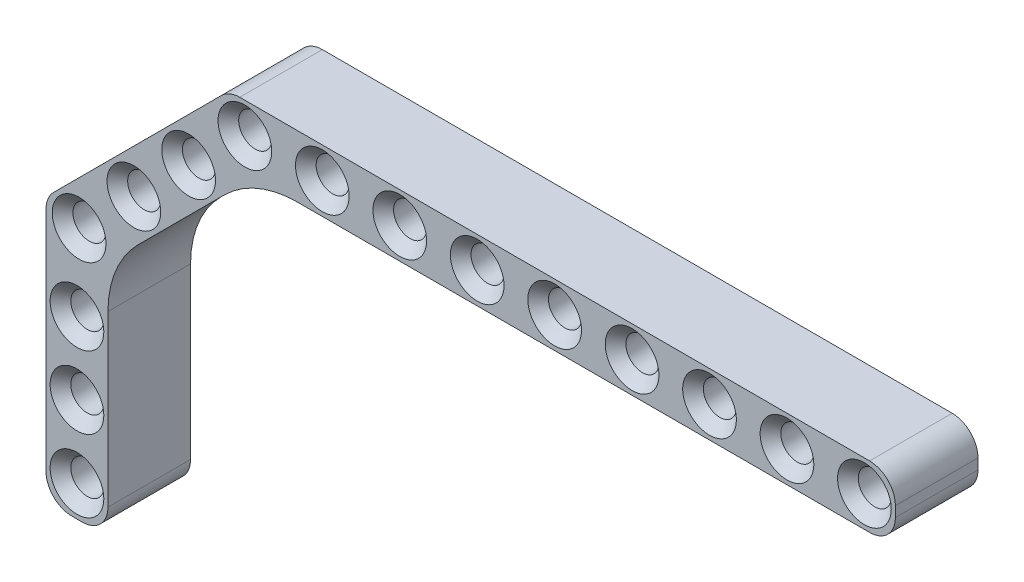
from build123d import *

# Parameters (mm, degrees)
SKETCH1_R           = 1.6
BOSS_EXTRUDE1_DEPTH = 8
CHAMFER1_SIZE       = 1
SKETCH2_R           = 1.6
BOSS_EXTRUDE3_DEPTH = 8
FILLET1_R           = 10
CHAMFER2_SIZE       = 1
CHAMFER3_SIZE       = 1
CHAMFER4_SIZE       = 1
SKETCH3_R           = 1.6
BOSS_EXTRUDE4_DEPTH = 8
CHAMFER5_SIZE       = 1
FILLET2_R           = 10


with BuildPart() as part:
    # Sketch1 → Boss-Extrude1 (new body)
    with BuildSketch(Plane.XY):
        with BuildLine():
            Line((-0.5, 3), (60.5, 3))
            ThreePointArc((60.5, 3), (62.267766953, 2.267766953), (63, 0.5))
            Line((63, 0.5), (63, -0.5))
            ThreePointArc((63, -0.5), (62.267766953, -2.267766953), (60.5, -3))
            Line((60.5, -3), (-0.5, -3))
            ThreePointArc((-0.5, -3), (-2.267766953, -2.267766953), (-3, -0.5))
            Line((-3, -0.5), (-3, 0.5))
            ThreePointArc((-3, 0.5), (-2.267766953, 2.267766953), (-0.5, 3))
        make_face()
        Circle(SKETCH1_R, mode=Mode.SUBTRACT)
        with Locations((7.5, 0)):
            Circle(SKETCH1_R, mode=Mode.SUBTRACT)
        with Locations((15, 0)):
            Circle(SKETCH1_R, mode=Mode.SUBTRACT)
        with Locations((22.5, 0)):
            Circle(SKETCH1_R, mode=Mode.SUBTRACT)
        with Locations((30, 0)):
            Circle(SKETCH1_R, mode=Mode.SUBTRACT)
        with Locations((37.5, 0)):
            Circle(SKETCH1_R, mode=Mode.SUBTRACT)
        with Locations((45, 0)):
            Circle(SKETCH1_R, mode=Mode.SUBTRACT)
        with Locations((52.5, 0)):
            Circle(SKETCH1_R, mode=Mode.SUBTRACT)
        with Locations((60, 0)):
            Circle(SKETCH1_R, mode=Mode.SUBTRACT)
    extrude(amount=BOSS_EXTRUDE1_DEPTH)

    # Chamfer1
    chamfer1_edges = [part.edges().sort_by_distance(p)[0] for p in [
        (-1.6, 0, 0),
        (-1.6, 0, 8),
        (5.9, 0, 0),
        (5.9, 0, 8),
        (13.4, 0, 0),
        (13.4, 0, 8),
        (20.9, 0, 0),
        (20.9, 0, 8),
        (28.4, 0, 0),
        (28.4, 0, 8),
    ]]
    chamfer(chamfer1_edges, length=CHAMFER1_SIZE)

    # Sketch2 → Boss-Extrude3 (add)
    with BuildSketch(Plane.XY.offset(8)):
        with BuildLine():
            ThreePointArc((-3, 0.5), (-2.809698831, 1.456708581), (-2.267766953, 2.267766953))
            Line((-2.267766953, 2.267766953), (-18.529200529, -13.993666623))
            ThreePointArc((-18.529200529, -13.993666623), (-19.261433576, -15.761433576), (-18.529200529, -17.529200529))
            Line((-18.529200529, -17.529200529), (-17.822093748, -18.23630731))
            ThreePointArc((-17.822093748, -18.23630731), (-16.054326795, -18.968540357), (-14.286559842, -18.23630731))
            Line((-14.286559842, -18.23630731), (0.949747468, -3))
            Line((0.949747468, -3), (-0.5, -3))
            ThreePointArc((-0.5, -3), (-2.267766953, -2.267766953), (-3, -0.5))
            Line((-3, -0.5), (-3, 0.5))
        make_face()
        with Locations((-16.054326795, -15.761433576)):
            Circle(SKETCH2_R, mode=Mode.SUBTRACT)
        with Locations((-10.751025936, -10.458132717)):
            Circle(SKETCH2_R, mode=Mode.SUBTRACT)
        with Locations((-5.447725077, -5.154831858)):
            Circle(SKETCH2_R, mode=Mode.SUBTRACT)
    extrude(amount=-BOSS_EXTRUDE3_DEPTH)

    # Fillet1
    fillet1_edges = [part.edges().sort_by_distance(p)[0] for p in [
        (0.949747468, -3, 4),
    ]]
    fillet(fillet1_edges, radius=FILLET1_R)

    # Chamfer2
    chamfer2_edges = [part.edges().sort_by_distance(p)[0] for p in [
        (-17.654326795, -15.761433576, 0),
        (-17.654326795, -15.761433576, 8),
        (-12.351025936, -10.458132717, 8),
        (-7.047725077, -5.154831858, 8),
        (-7.047725077, -5.154831858, 0),
        (-12.351025936, -10.458132717, 0),
    ]]
    chamfer(chamfer2_edges, length=CHAMFER2_SIZE)

    # Chamfer3
    chamfer3_edges = [part.edges().sort_by_distance(p)[0] for p in [
        (35.9, 0, 0),
        (35.9, 0, 8),
        (43.4, 0, 0),
        (43.4, 0, 8),
    ]]
    chamfer(chamfer3_edges, length=CHAMFER3_SIZE)

    # Chamfer4
    chamfer4_edges = [part.edges().sort_by_distance(p)[0] for p in [
        (50.9, 0, 0),
        (50.9, 0, 8),
        (58.4, 0, 0),
        (58.4, 0, 8),
    ]]
    chamfer(chamfer4_edges, length=CHAMFER4_SIZE)

    # Sketch3 → Boss-Extrude4 (add)
    with BuildSketch(Plane.XY.offset(8)):
        with BuildLine():
            ThreePointArc((-18.529200529, -17.529200529), (-19.071132407, -16.718142157), (-19.261433576, -15.761433576))
            Line((-19.261433576, -15.761433576), (-19.261433576, -37.761433576))
            ThreePointArc((-19.261433576, -37.761433576), (-18.529200529, -39.529200529), (-16.761433576, -40.261433576))
            Line((-16.761433576, -40.261433576), (-15.761433576, -40.261433576))
            ThreePointArc((-15.761433576, -40.261433576), (-13.993666623, -39.529200529), (-13.261433576, -37.761433576))
            Line((-13.261433576, -37.761433576), (-13.261433576, -17.211181044))
            Line((-13.261433576, -17.211181044), (-14.286559842, -18.23630731))
            ThreePointArc((-14.286559842, -18.23630731), (-16.054326795, -18.968540357), (-17.822093748, -18.23630731))
            Line((-17.822093748, -18.23630731), (-18.529200529, -17.529200529))
        make_face()
        with Locations((-16.261433576, -30.261433576)):
            Circle(SKETCH3_R, mode=Mode.SUBTRACT)
        with Locations((-16.261433576, -37.261433576)):
            Circle(SKETCH3_R, mode=Mode.SUBTRACT)
        with Locations((-16.261433576, -23.261433576)):
            Circle(SKETCH3_R, mode=Mode.SUBTRACT)
    extrude(amount=-BOSS_EXTRUDE4_DEPTH)

    # Chamfer5
    chamfer5_edges = [part.edges().sort_by_distance(p)[0] for p in [
        (-17.861433576, -37.261433576, 8),
        (-17.861433576, -30.261433576, 8),
        (-17.861433576, -23.261433576, 8),
        (-17.861433576, -23.261433576, 0),
        (-17.861433576, -30.261433576, 0),
        (-17.861433576, -37.261433576, 0),
    ]]
    chamfer(chamfer5_edges, length=CHAMFER5_SIZE)

    # Fillet2
    fillet2_edges = [part.edges().sort_by_distance(p)[0] for p in [
        (-13.261433576, -17.211181044, 4),
    ]]
    fillet(fillet2_edges, radius=FILLET2_R)


solid = part.part
